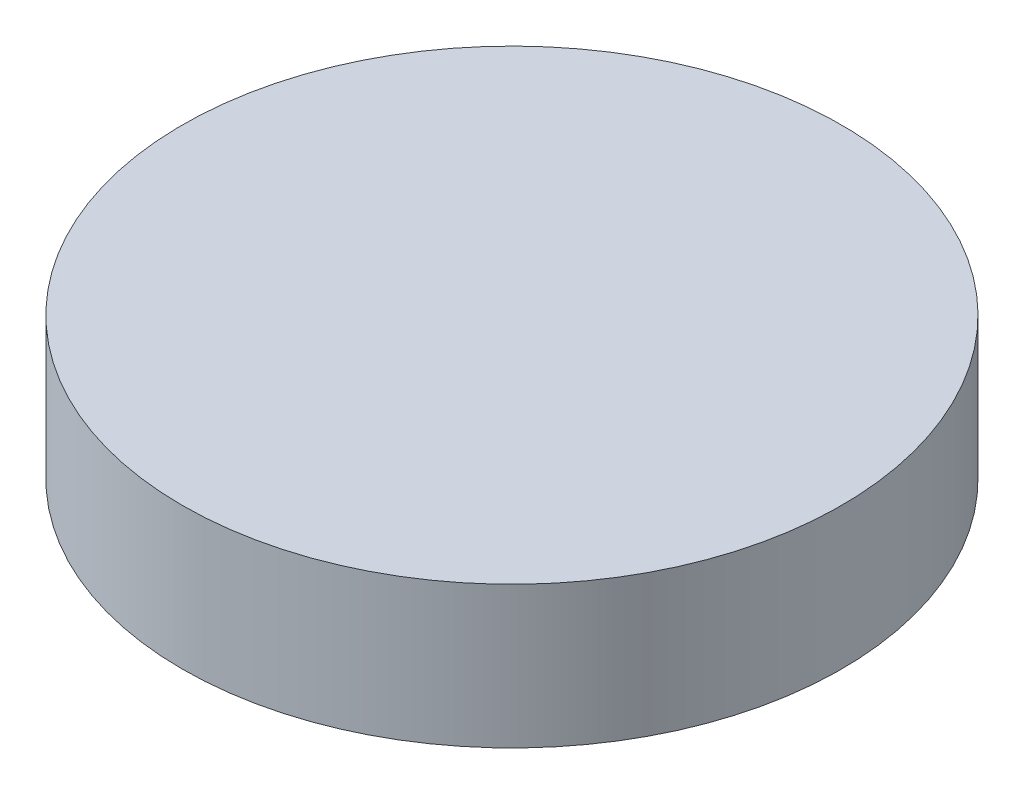
from build123d import *

# Parameters (mm, degrees)
SKETCH1_R           = 21.5
SKETCH1_R_2         = 20
BOSS_EXTRUDE1_DEPTH = 7.5
SKETCH2_R           = 21.5
BOSS_EXTRUDE2_DEPTH = 1.75


with BuildPart() as part:
    # Sketch1 → Boss-Extrude1 (new body)
    with BuildSketch(Plane(origin=(0, 0, 0), x_dir=(1, 0, 0), z_dir=(0, 1, 0))):
        Circle(SKETCH1_R)
        Circle(SKETCH1_R_2, mode=Mode.SUBTRACT)
    extrude(amount=BOSS_EXTRUDE1_DEPTH)

    # Sketch2 → Boss-Extrude2 (add)
    with BuildSketch(Plane(origin=(0, 7.5, 0), x_dir=(1, 0, 0), z_dir=(0, 1, 0))):
        Circle(SKETCH2_R)
    extrude(amount=BOSS_EXTRUDE2_DEPTH)


solid = part.part
